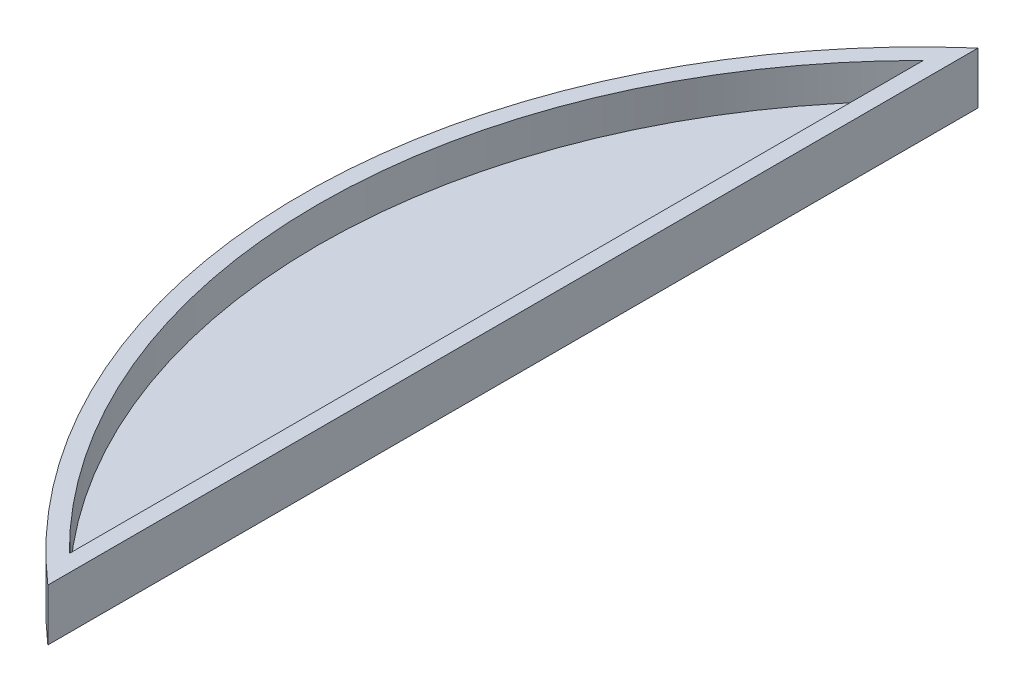
from build123d import *

# Parameters (mm, degrees)
BOSS_EXTRUDE1_DEPTH = 6.35
SHELL1_T            = -2.032


with BuildPart() as part:
    # Sketch1 → Boss-Extrude1 (new body)
    with BuildSketch(Plane(origin=(0, 0, 0), x_dir=(1, 0, 0), z_dir=(0, 1, 0))):
        with BuildLine():
            Line((0, -113.792), (0, 0))
            ThreePointArc((0, 0), (-25.836593541, -56.896), (0, -113.792))
        make_face()
    extrude(amount=BOSS_EXTRUDE1_DEPTH)

    # Shell1
    shell1_openings = [part.faces().sort_by_distance(p)[0] for p in [
        (-12.91829677, 6.35, 56.896),
    ]]
    offset(amount=SHELL1_T, openings=shell1_openings)


solid = part.part
